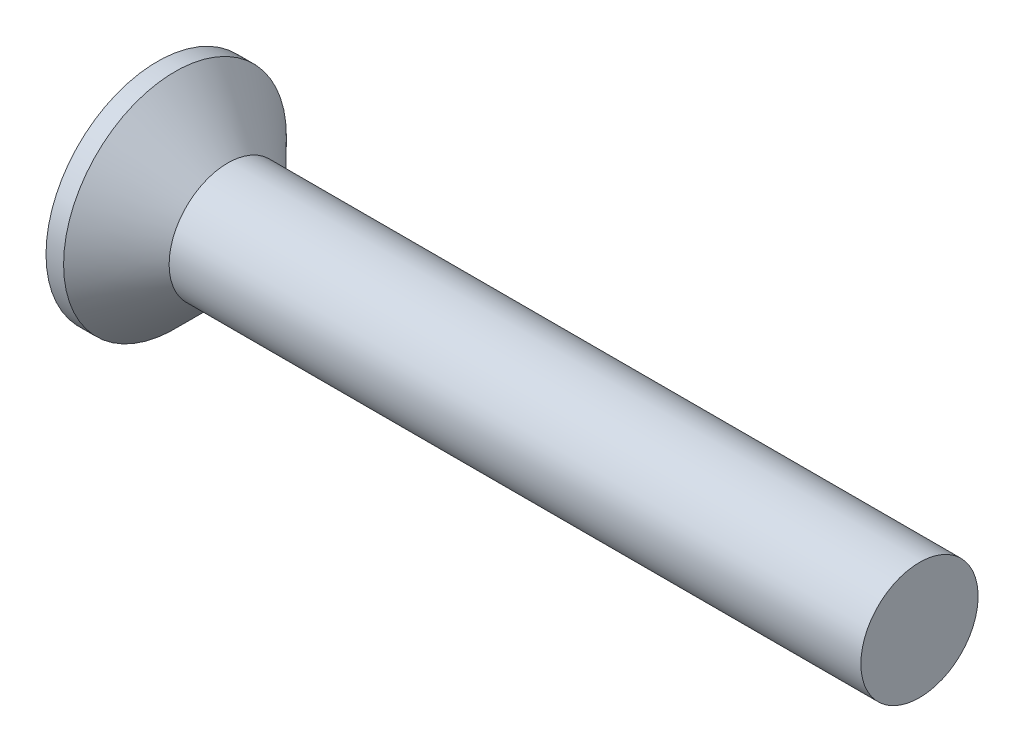
from build123d import *

# Parameters (mm, degrees)
SKETCH3_W         = 0.53
SKETCH3_H         = 2.14
SKETCH4_W         = 0.265
SKETCH4_H         = 0.265
CIRPATTERN1_COUNT = 2
CIRPATTERN1_ANGLE = 90


with BuildPart() as part:
    # BodySke → Base-Revolve (revolve)
    with BuildSketch(Plane.XY):
        Polygon((0, 0), (0, 1.9), (0.3, 1.9), (1.2, 1), (13, 1), (13, 0), align=None)
    revolve(axis=Axis((-6.35, 0, 0), (1, 0, 0)))

    # Sketch3 → Cross section 0
    with BuildSketch(Plane.ZY):
        Rectangle(SKETCH3_W, SKETCH3_H)
    # Sketch4 → Cross section 1
    with BuildSketch(Plane.ZY.offset(-1.54)):
        Rectangle(SKETCH4_W, SKETCH4_H)
    cross = loft(mode=Mode.SUBTRACT)

    # CirPattern1: Cross ×2 about axis
    cirpattern1_axis = Axis((0, 0, 0), (1, 0, 0))
    for i in range(1, CIRPATTERN1_COUNT):
        add(cross.rotate(cirpattern1_axis, i * CIRPATTERN1_ANGLE / (CIRPATTERN1_COUNT - 1)), mode=Mode.SUBTRACT)


solid = part.part
